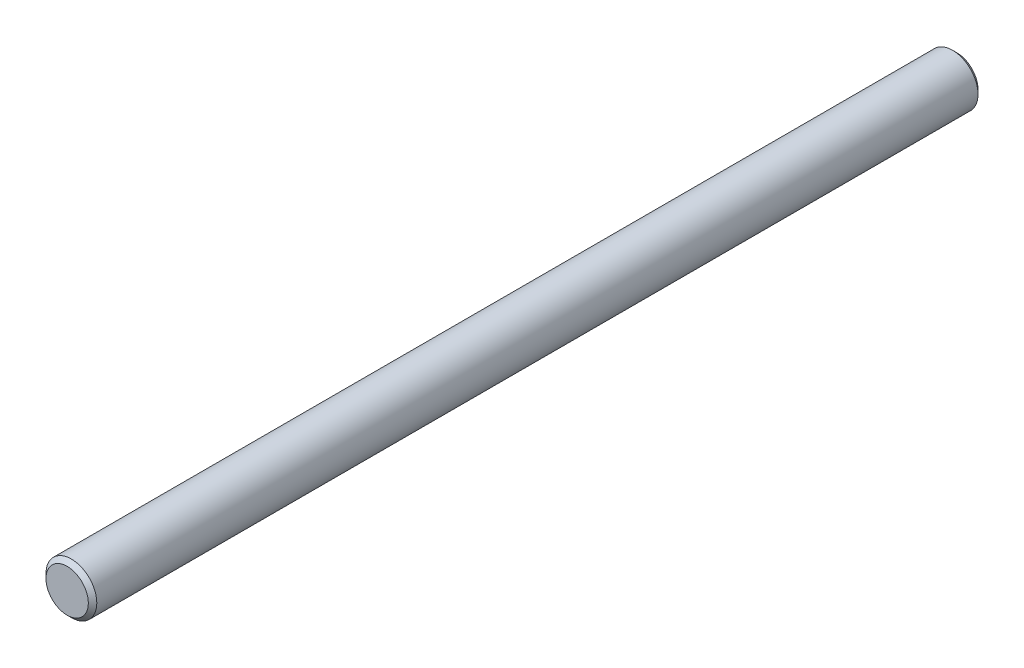
from build123d import *

# Parameters (mm, degrees)
SKETCH_1_R      = 6
EXTRUDE_1_DEPTH = 210
CHAMFER_1_SIZE  = 1


with BuildPart() as part:
    # Эскиз1 → Бобышка-Вытянуть1 (new body)
    with BuildSketch(Plane.XY):
        Circle(SKETCH_1_R)
    extrude(amount=EXTRUDE_1_DEPTH)

    # Фаска1
    chamfer_1_edges = [part.edges().sort_by_distance(p)[0] for p in [
        (-6, 0, 0),
        (-6, 0, 210),
    ]]
    chamfer(chamfer_1_edges, length=CHAMFER_1_SIZE)


solid = part.part
